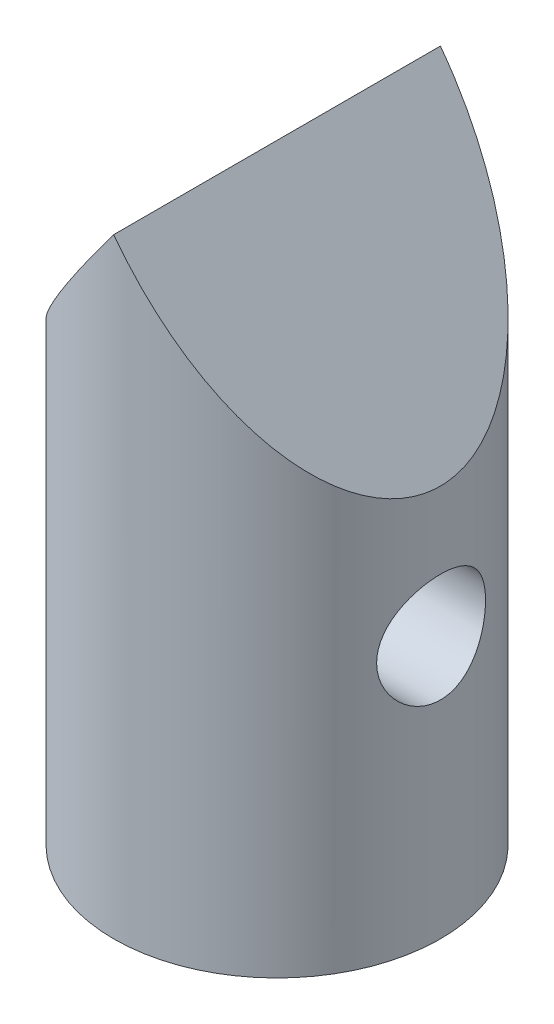
from build123d import *

# Parameters (mm, degrees)
SKETCH1_R               = 4.7625
BOSS_EXTRUDE1_DEPTH     = 17.78
CUT_EXTRUDE1_DEPTH      = 17.78
CUT_EXTRUDE1_DEPTH_BACK = 17.78
CUT_EXTRUDE2_DEPTH      = 17.78
CUT_EXTRUDE2_DEPTH_BACK = 17.78
CUT_EXTRUDE3_DEPTH      = 17.78
CUT_EXTRUDE3_DEPTH_BACK = 17.78
SKETCH4_R               = 1.5875


with BuildPart() as part:
    # Sketch1 → Boss-Extrude1 (new body)
    with BuildSketch(Plane(origin=(0, 0, 0), x_dir=(1, 0, 0), z_dir=(0, 1, 0))):
        Circle(SKETCH1_R)
    extrude(amount=BOSS_EXTRUDE1_DEPTH)

    # Sketch2 → Cut-Extrude1 (cut, two sides: drawn at the far end of the back side and taken through both)
    with BuildSketch(Plane.XY.offset(-CUT_EXTRUDE1_DEPTH_BACK)):
        Polygon((-4.7625, 17.78), (0, 17.78), (-4.7625, 11.43), align=None)
    extrude(amount=CUT_EXTRUDE1_DEPTH + CUT_EXTRUDE1_DEPTH_BACK, mode=Mode.SUBTRACT)

    # Sketch3 → Cut-Extrude2 (cut, two sides: drawn at the far end of the back side and taken through both)
    with BuildSketch(Plane.XY.offset(-CUT_EXTRUDE2_DEPTH_BACK)):
        Polygon((0, 17.78), (4.7625, 17.78), (4.7625, 11.43), align=None)
    extrude(amount=CUT_EXTRUDE2_DEPTH + CUT_EXTRUDE2_DEPTH_BACK, mode=Mode.SUBTRACT)

    # Sketch4 → Cut-Extrude3 (cut, two sides: drawn at the far end of the back side and taken through both)
    with BuildSketch(Plane(origin=(0, 0, 0), x_dir=(0, 0, -1), z_dir=(1, 0, 0)).offset(-CUT_EXTRUDE3_DEPTH_BACK)):
        with Locations((0, 7.62)):
            Circle(SKETCH4_R)
    extrude(amount=CUT_EXTRUDE3_DEPTH + CUT_EXTRUDE3_DEPTH_BACK, mode=Mode.SUBTRACT)


solid = part.part
